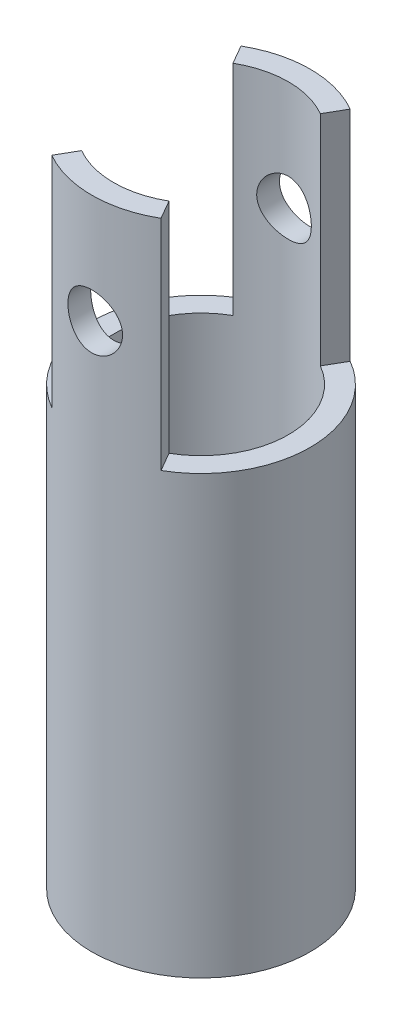
from build123d import *

# Parameters (mm, degrees)
SKETCH_1_R               = 1
SKETCH_1_R_2             = 0.8
EXTRUDE_1_DEPTH          = 6
CUT_EXTRUDE_START        = -2
CUT_EXTRUDE_2_DEPTH      = 2
CUT_EXTRUDE_3_DEPTH      = 2
CUT_EXTRUDE_3_DEPTH_BACK = 2
SKETCH_4_R               = 0.25


with BuildPart() as part:
    # 草图1 → 凸台-拉伸1 (new body)
    with BuildSketch(Plane(origin=(0, 0, 0), x_dir=(1, 0, 0), z_dir=(0, 1, 0))):
        Circle(SKETCH_1_R)
        Circle(SKETCH_1_R_2, mode=Mode.SUBTRACT)
    extrude(amount=EXTRUDE_1_DEPTH)

    # 草图2 → 切除-拉伸2 (cut)
    with BuildSketch(Plane(origin=(0, 6, 0), x_dir=(1, 0, 0), z_dir=(0, 1, 0)).offset(CUT_EXTRUDE_START)):
        with BuildLine():
            ThreePointArc((-0.5, 0.866025404), (-1, 0), (-0.5, -0.866025404))
            Line((-0.5, -0.866025404), (0, 0))
            Line((0, 0), (-0.5, 0.866025404))
        make_face()
        with BuildLine():
            Line((0.5, 0.866025404), (0, 0))
            Line((0, 0), (0.5, -0.866025404))
            ThreePointArc((0.5, -0.866025404), (1, 0), (0.5, 0.866025404))
        make_face()
    extrude(amount=CUT_EXTRUDE_2_DEPTH, mode=Mode.SUBTRACT)

    # 草图4 → 切除-拉伸3 (cut, two sides: drawn at the far end of the back side and taken through both)
    with BuildSketch(Plane.XY.offset(-CUT_EXTRUDE_3_DEPTH_BACK)):
        with Locations((0, 5)):
            Circle(SKETCH_4_R)
    extrude(amount=CUT_EXTRUDE_3_DEPTH + CUT_EXTRUDE_3_DEPTH_BACK, mode=Mode.SUBTRACT)


solid = part.part
